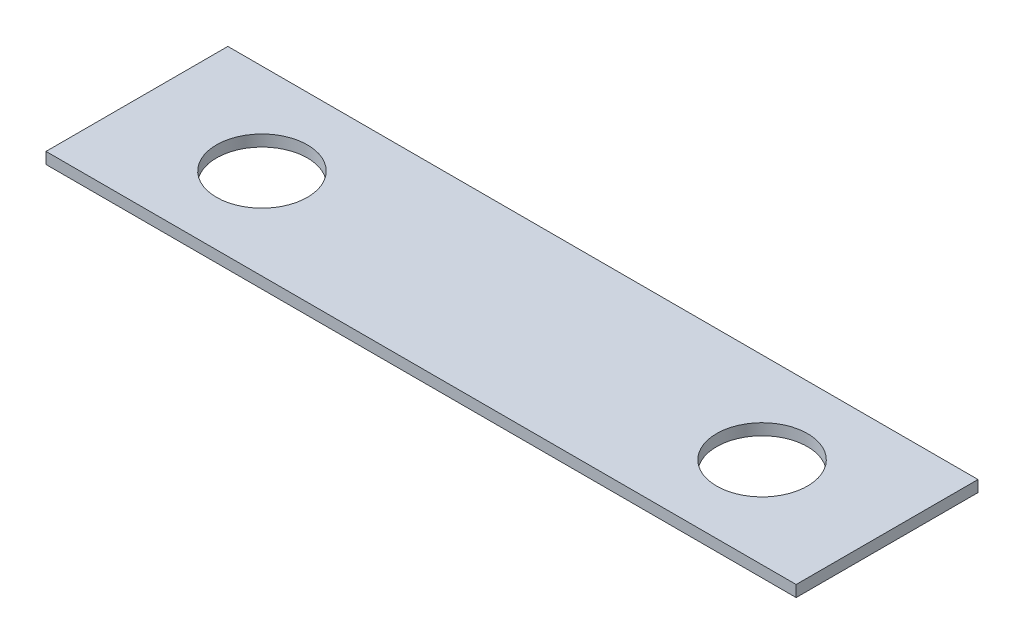
from build123d import *

# Parameters (mm, degrees)
SKETCH1_W           = 33
SKETCH1_H           = 8
SKETCH1_R           = 2
BOSS_EXTRUDE1_DEPTH = 0.5


with BuildPart() as part:
    # Sketch1 → Boss-Extrude1 (new body)
    with BuildSketch(Plane(origin=(0, 0, 0), x_dir=(1, 0, 0), z_dir=(0, 1, 0))):
        Rectangle(SKETCH1_W, SKETCH1_H)
        with Locations((-11, 0)):
            Circle(SKETCH1_R, mode=Mode.SUBTRACT)
        with Locations((11, 0)):
            Circle(SKETCH1_R, mode=Mode.SUBTRACT)
    extrude(amount=BOSS_EXTRUDE1_DEPTH)


solid = part.part
